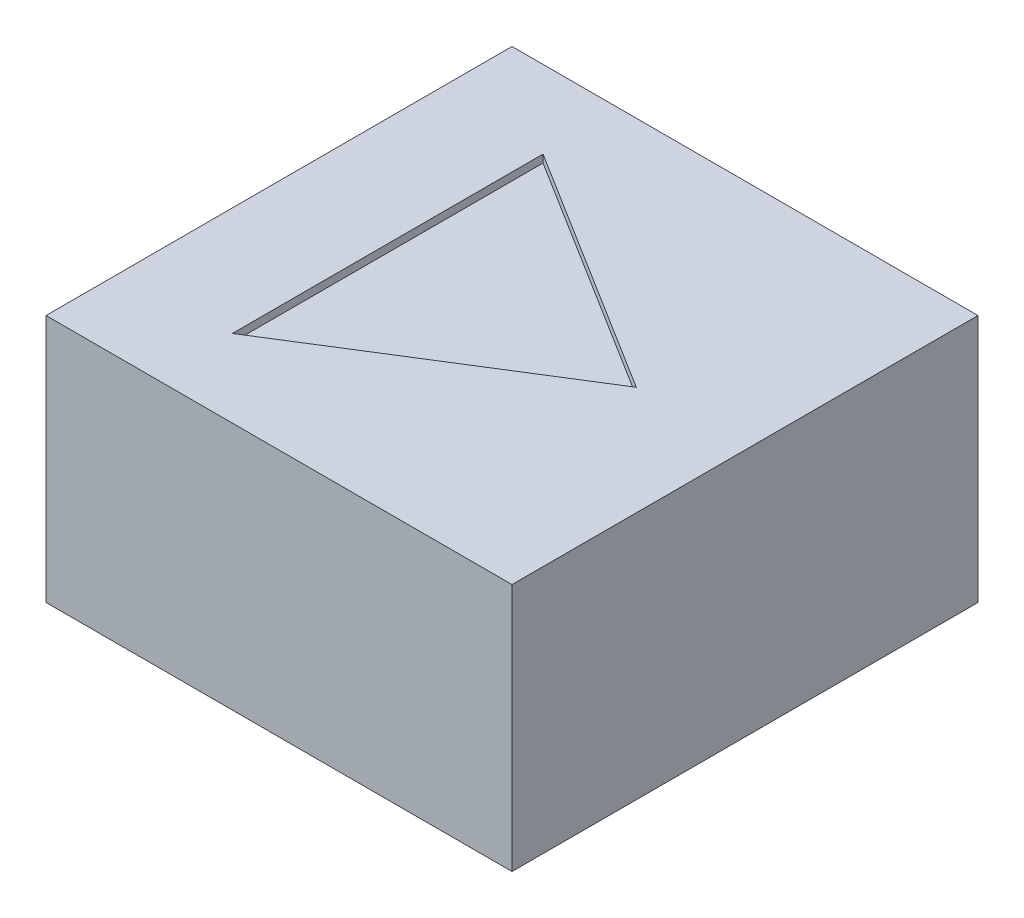
from build123d import *

# Parameters (mm, degrees)
SKETCH1_W           = 15
SKETCH1_H           = 15
BOSS_EXTRUDE1_DEPTH = 8
SKETCH2_R           = 1
CUT_EXTRUDE1_DEPTH  = 1.5
CUT_EXTRUDE2_DEPTH  = 4
SKETCH4_W           = 4.4
SKETCH4_H           = 4.4
CUT_EXTRUDE3_DEPTH  = 2.75
CUT_EXTRUDE4_DEPTH  = 0.25
FILLET1_R           = 0.75


with BuildPart() as part:
    # Sketch1 → Boss-Extrude1 (new body)
    with BuildSketch(Plane(origin=(0, 0, 0), x_dir=(1, 0, 0), z_dir=(0, 1, 0))):
        Rectangle(SKETCH1_W, SKETCH1_H)
    extrude(amount=BOSS_EXTRUDE1_DEPTH)

    # Sketch2 → Cut-Extrude1 (cut)
    with BuildSketch(Plane.XZ):
        with Locations((-3.889087297, 3.889087297)):
            Circle(SKETCH2_R)
        with Locations((3.889087297, -3.889087297)):
            Circle(SKETCH2_R)
        with Locations((-3.889087297, -3.889087297)):
            Circle(SKETCH2_R)
        with Locations((3.889087297, 3.889087297)):
            Circle(SKETCH2_R)
    extrude(amount=-CUT_EXTRUDE1_DEPTH, mode=Mode.SUBTRACT)

    # Sketch3 → Cut-Extrude2 (cut)
    with BuildSketch(Plane.XZ):
        Polygon((-0.707106781, 0), (-1.75, 1.042893219), (-1.75, -1.042893219), align=None)
        Polygon((-0.707106781, 0), (-1.75, -1.042893219), (-1.75, -1.75), (-1.042893219, -1.75), (0, -0.707106781), align=None)
        Polygon((1.042893219, -1.75), (0, -0.707106781), (-1.042893219, -1.75), align=None)
        Polygon((1.75, -1.042893219), (0.707106781, 0), (0, -0.707106781), (1.042893219, -1.75), (1.75, -1.75), align=None)
        Polygon((1.75, 1.042893219), (0.707106781, 0), (1.75, -1.042893219), align=None)
        Polygon((1.75, 1.75), (1.042893219, 1.75), (0, 0.707106781), (0.707106781, 0), (1.75, 1.042893219), align=None)
        Polygon((1.042893219, 1.75), (-1.042893219, 1.75), (0, 0.707106781), align=None)
        Polygon((0, 0.707106781), (-1.042893219, 1.75), (-1.75, 1.75), (-1.75, 1.042893219), (-0.707106781, 0), align=None)
        Polygon((0.707106781, 0), (0, 0.707106781), (-0.707106781, 0), (0, -0.707106781), align=None)
        Polygon((-2.442893219, 3.15), (-3.15, 3.15), (-3.15, 2.442893219), (-1.75, 1.042893219), (-1.75, 1.75), (-1.042893219, 1.75), align=None)
        Polygon((3.15, 3.15), (2.442893219, 3.15), (1.042893219, 1.75), (1.75, 1.75), (1.75, 1.042893219), (3.15, 2.442893219), align=None)
        Polygon((3.15, -3.15), (3.15, -2.442893219), (1.75, -1.042893219), (1.75, -1.75), (1.042893219, -1.75), (2.442893219, -3.15), align=None)
        Polygon((-1.75, -1.042893219), (-3.15, -2.442893219), (-3.15, -3.15), (-2.442893219, -3.15), (-1.042893219, -1.75), (-1.75, -1.75), align=None)
        with BuildLine():
            Line((-3.15, -2.442893219), (-3.15, 2.442893219))
            Line((-3.15, 2.442893219), (-3.630268251, 2.92316147))
            ThreePointArc((-3.630268251, 2.92316147), (-3.758561104, 2.897642435), (-3.889087297, 2.889087297))
            Line((-3.889087297, 2.889087297), (-3.889087297, -2.889087297))
            ThreePointArc((-3.889087297, -2.889087297), (-3.758561104, -2.897642435), (-3.630268251, -2.92316147))
            Line((-3.630268251, -2.92316147), (-3.15, -2.442893219))
        make_face()
        with BuildLine():
            Line((3.630268251, 2.92316147), (3.15, 2.442893219))
            Line((3.15, 2.442893219), (3.15, -2.442893219))
            Line((3.15, -2.442893219), (3.630268251, -2.92316147))
            ThreePointArc((3.630268251, -2.92316147), (3.758561104, -2.897642435), (3.889087297, -2.889087297))
            Line((3.889087297, -2.889087297), (3.889087297, 2.889087297))
            ThreePointArc((3.889087297, 2.889087297), (3.758561104, 2.897642435), (3.630268251, 2.92316147))
        make_face()
        with BuildLine():
            Line((2.92316147, 3.630268251), (2.442893219, 3.15))
            Line((2.442893219, 3.15), (3.15, 3.15))
            Line((3.15, 3.15), (3.15, 2.442893219))
            Line((3.15, 2.442893219), (3.630268251, 2.92316147))
            ThreePointArc((3.630268251, 2.92316147), (3.181980515, 3.181980515), (2.92316147, 3.630268251))
        make_face()
        with BuildLine():
            Line((-2.92316147, 3.630268251), (-2.442893219, 3.15))
            Line((-2.442893219, 3.15), (2.442893219, 3.15))
            Line((2.442893219, 3.15), (2.92316147, 3.630268251))
            ThreePointArc((2.92316147, 3.630268251), (2.897642435, 3.758561104), (2.889087297, 3.889087297))
            Line((2.889087297, 3.889087297), (-2.889087297, 3.889087297))
            ThreePointArc((-2.889087297, 3.889087297), (-2.897642435, 3.758561104), (-2.92316147, 3.630268251))
        make_face()
        with BuildLine():
            Line((-3.15, -3.15), (-3.15, -2.442893219))
            Line((-3.15, -2.442893219), (-3.630268251, -2.92316147))
            ThreePointArc((-3.630268251, -2.92316147), (-3.181980515, -3.181980515), (-2.92316147, -3.630268251))
            Line((-2.92316147, -3.630268251), (-2.442893219, -3.15))
            Line((-2.442893219, -3.15), (-3.15, -3.15))
        make_face()
        with BuildLine():
            Line((2.442893219, -3.15), (-2.442893219, -3.15))
            Line((-2.442893219, -3.15), (-2.92316147, -3.630268251))
            ThreePointArc((-2.92316147, -3.630268251), (-2.897642435, -3.758561104), (-2.889087297, -3.889087297))
            Line((-2.889087297, -3.889087297), (2.889087297, -3.889087297))
            ThreePointArc((2.889087297, -3.889087297), (2.897642435, -3.758561104), (2.92316147, -3.630268251))
            Line((2.92316147, -3.630268251), (2.442893219, -3.15))
        make_face()
        with BuildLine():
            Line((3.630268251, -2.92316147), (3.15, -2.442893219))
            Line((3.15, -2.442893219), (3.15, -3.15))
            Line((3.15, -3.15), (2.442893219, -3.15))
            Line((2.442893219, -3.15), (2.92316147, -3.630268251))
            ThreePointArc((2.92316147, -3.630268251), (3.181980515, -3.181980515), (3.630268251, -2.92316147))
        make_face()
        with BuildLine():
            Line((-3.15, 2.442893219), (-3.15, 3.15))
            Line((-3.15, 3.15), (-2.442893219, 3.15))
            Line((-2.442893219, 3.15), (-2.92316147, 3.630268251))
            ThreePointArc((-2.92316147, 3.630268251), (-3.181980515, 3.181980515), (-3.630268251, 2.92316147))
            Line((-3.630268251, 2.92316147), (-3.15, 2.442893219))
        make_face()
    extrude(amount=-CUT_EXTRUDE2_DEPTH, mode=Mode.SUBTRACT)

    # Sketch4 → Cut-Extrude3 (cut)
    with BuildSketch(Plane.XZ.offset(-4)):
        Rectangle(SKETCH4_W, SKETCH4_H)
    extrude(amount=CUT_EXTRUDE3_DEPTH, mode=Mode.SUBTRACT)

    # Sketch5 → Cut-Extrude4 (cut)
    with BuildSketch(Plane(origin=(0, 8, 0), x_dir=(1, 0, 0), z_dir=(0, 1, 0))):
        Polygon((4, 0), (-4, 5), (-4, -5), align=None)
    extrude(amount=-CUT_EXTRUDE4_DEPTH, mode=Mode.SUBTRACT)

    # Fillet1
    fillet1_edges = [part.edges().sort_by_distance(p)[0] for p in [
        (0, 0, 1.75),
        (1.75, 0, 0),
        (0, 0, -1.75),
        (-1.75, 0, 0),
    ]]
    fillet(fillet1_edges, radius=FILLET1_R)


solid = part.part
